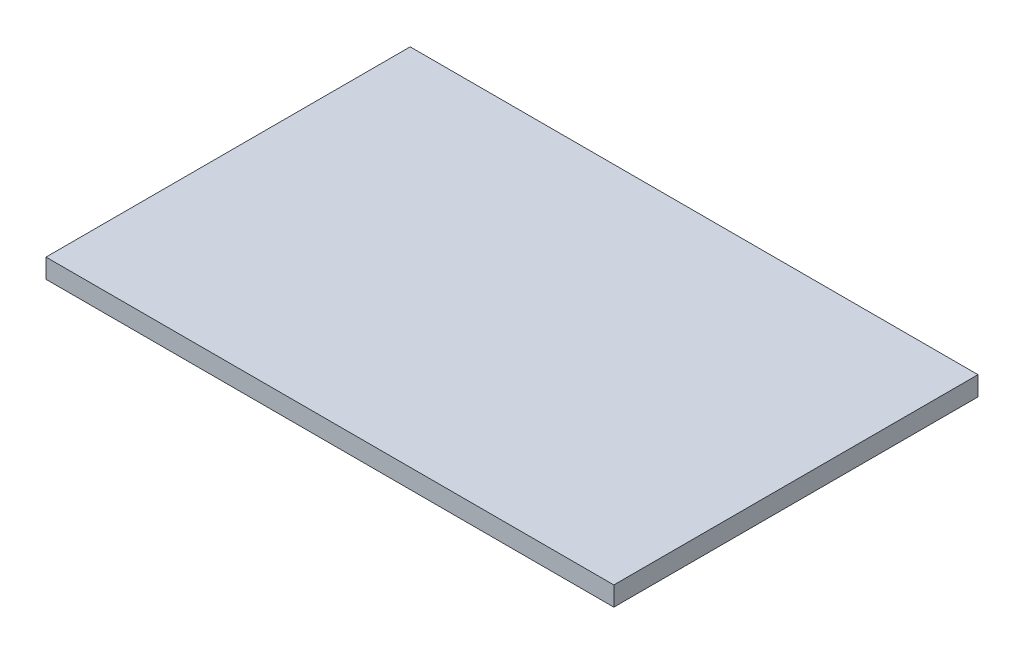
from build123d import *

# Parameters (mm, degrees)
SKETCH1_W           = 467.36
SKETCH1_H           = 299.72
BOSS_EXTRUDE1_DEPTH = 15.875


with BuildPart() as part:
    # Sketch1 → Boss-Extrude1 (new body)
    with BuildSketch(Plane(origin=(0, 0, 0), x_dir=(1, 0, 0), z_dir=(0, 1, 0))):
        with Locations((233.68, 149.86)):
            Rectangle(SKETCH1_W, SKETCH1_H)
    extrude(amount=BOSS_EXTRUDE1_DEPTH)


solid = part.part
